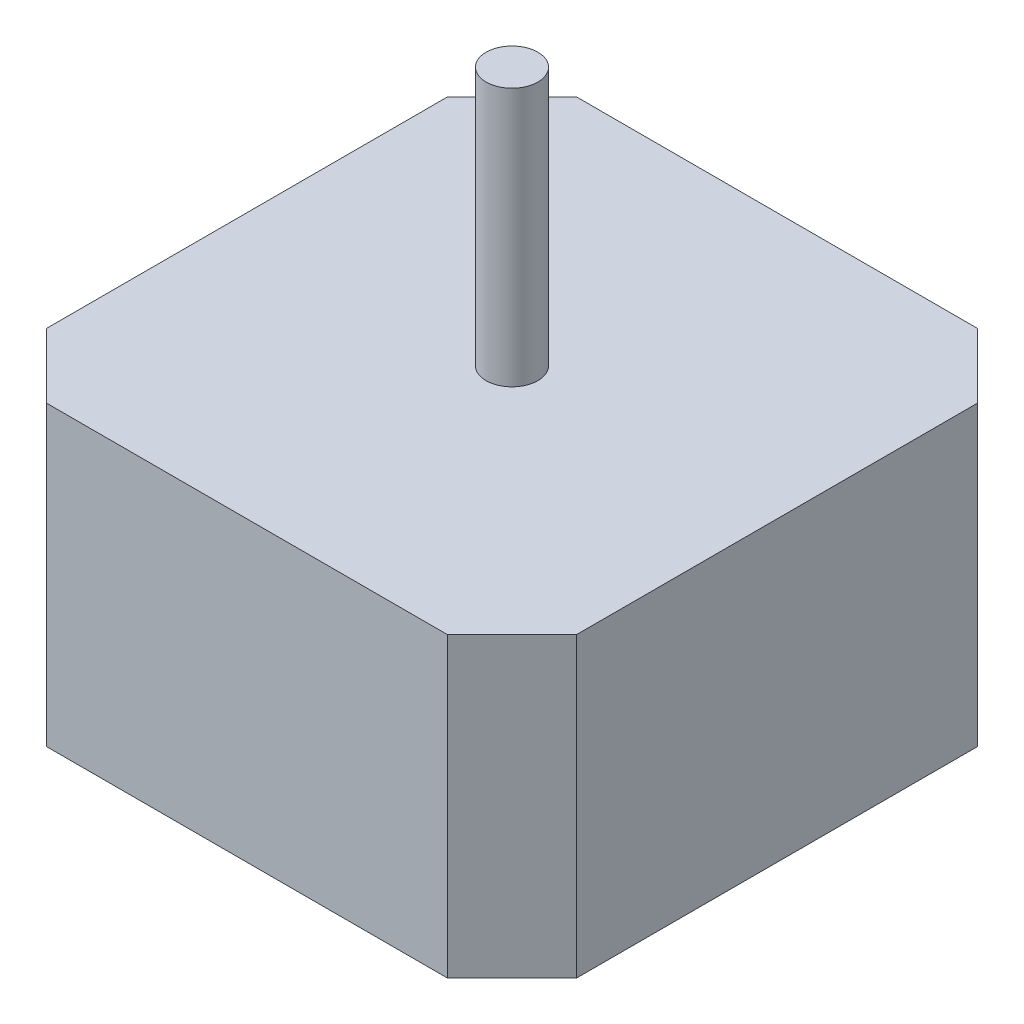
from build123d import *

# Parameters (mm, degrees)
SKETCH2_W            = 41
SKETCH2_H            = 41
SKETCH2_W_2          = 14.993938253
SKETCH2_H_2          = 4.00275912
BOSS_EXTRUDE7_DEPTH  = 23
CUT_EXTRUDE1_DEPTH   = 23
CUT_EXTRUDE3_DEPTH   = 23
SKETCH8_W            = 14.993938253
SKETCH8_H            = 4.00275912
CUT_EXTRUDE4_DEPTH   = 14
SKETCH3_R            = 2
BOSS_EXTRUDE11_DEPTH = 20


with BuildPart() as part:
    # Sketch2 → Boss-Extrude7 (new body)
    with BuildSketch(Plane(origin=(0, 0, 0), x_dir=(1, 0, 0), z_dir=(0, 1, 0))):
        Rectangle(SKETCH2_W, SKETCH2_H)
        with Locations((0.012281963, 22.50137956)):
            Rectangle(SKETCH2_W_2, SKETCH2_H_2)
    extrude(amount=BOSS_EXTRUDE7_DEPTH)

    # Sketch6 → Cut-Extrude1 (cut)
    with BuildSketch(Plane(origin=(0, 0, 0), x_dir=(1, 0, 0), z_dir=(0, 1, 0))):
        Polygon((-20.5, 20.5), (-15.5, 20.5), (-20.5, 15.5), align=None)
    extrude(amount=CUT_EXTRUDE1_DEPTH, mode=Mode.SUBTRACT)

    # Sketch7 → Cut-Extrude3 (cut)
    with BuildSketch(Plane(origin=(0, 0, 0), x_dir=(1, 0, 0), z_dir=(0, 1, 0))):
        Polygon((-20.5, -20.5), (-20.5, -15.5), (-15.5, -20.5), align=None)
        Polygon((20.5, -20.5), (15.5, -20.5), (20.5, -15.5), align=None)
        Polygon((20.5, 20.5), (20.5, 15.5), (15.5, 20.5), align=None)
    extrude(amount=CUT_EXTRUDE3_DEPTH, mode=Mode.SUBTRACT)

    # Sketch8 → Cut-Extrude4 (cut)
    with BuildSketch(Plane(origin=(0, 23, 0), x_dir=(1, 0, 0), z_dir=(0, 1, 0))):
        with Locations((0.012281963, 22.50137956)):
            Rectangle(SKETCH8_W, SKETCH8_H)
    extrude(amount=-CUT_EXTRUDE4_DEPTH, mode=Mode.SUBTRACT)

    # Sketch3 → Boss-Extrude11 (add)
    with BuildSketch(Plane(origin=(0, 23, 0), x_dir=(1, 0, 0), z_dir=(0, 1, 0))):
        Circle(SKETCH3_R)
    extrude(amount=BOSS_EXTRUDE11_DEPTH)


solid = part.part
